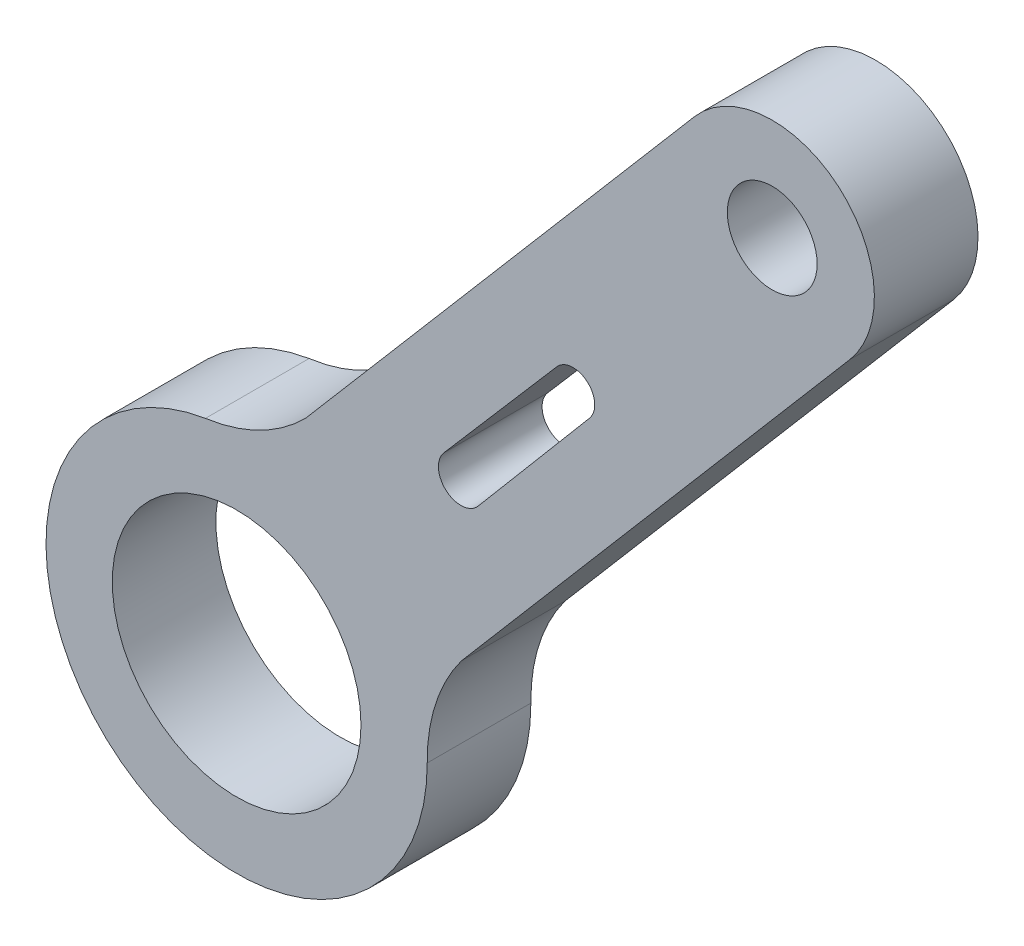
from build123d import *

# Parameters (mm, degrees)
MODEL_R             = 3.6
MODEL_R_2           = 1.3
BOSS_EXTRUDE1_DEPTH = 3


with BuildPart() as part:
    # Model → Boss-Extrude1 (new body)
    with BuildSketch(Plane.XY):
        with BuildLine():
            Line((58.068440008, 48.533872703), (46.830105606, 35.365817257))
            ThreePointArc((46.830105606, 35.365817257), (46.085714126, 33.921588349), (45.843713156, 32.314929909))
            ThreePointArc((45.843713156, 32.314929909), (36.762881301, 28.086852553), (39.424151137, 37.743756206))
            ThreePointArc((39.424151137, 37.743756206), (41.006745997, 38.235421473), (42.341707312, 39.217368271))
            Line((42.341707312, 39.217368271), (53.580041714, 52.385423717))
            ThreePointArc((53.580041714, 52.385423717), (57.749130002, 52.715057779), (58.078764064, 48.54596949))
            Line((58.078764064, 48.54596949), (58.068440008, 48.533872703))
        make_face()
        with Locations((40.325895646, 32.300100558)):
            Circle(MODEL_R, mode=Mode.SUBTRACT)
        with Locations((55.829402889, 50.465696604)):
            Circle(MODEL_R_2, mode=Mode.SUBTRACT)
        with BuildLine():
            Line((47.314287018, 39.487196923), (50.544132712, 43.310523772))
            ThreePointArc((50.544132712, 43.310523772), (50.470318272, 44.19097138), (49.589870666, 44.117156913))
            Line((49.589870666, 44.117156913), (46.321463386, 40.326423493))
            ThreePointArc((46.321463386, 40.326423493), (46.398261906, 39.41039838), (47.314287018, 39.487196923))
        make_face(mode=Mode.SUBTRACT)
    extrude(amount=BOSS_EXTRUDE1_DEPTH)


solid = part.part
